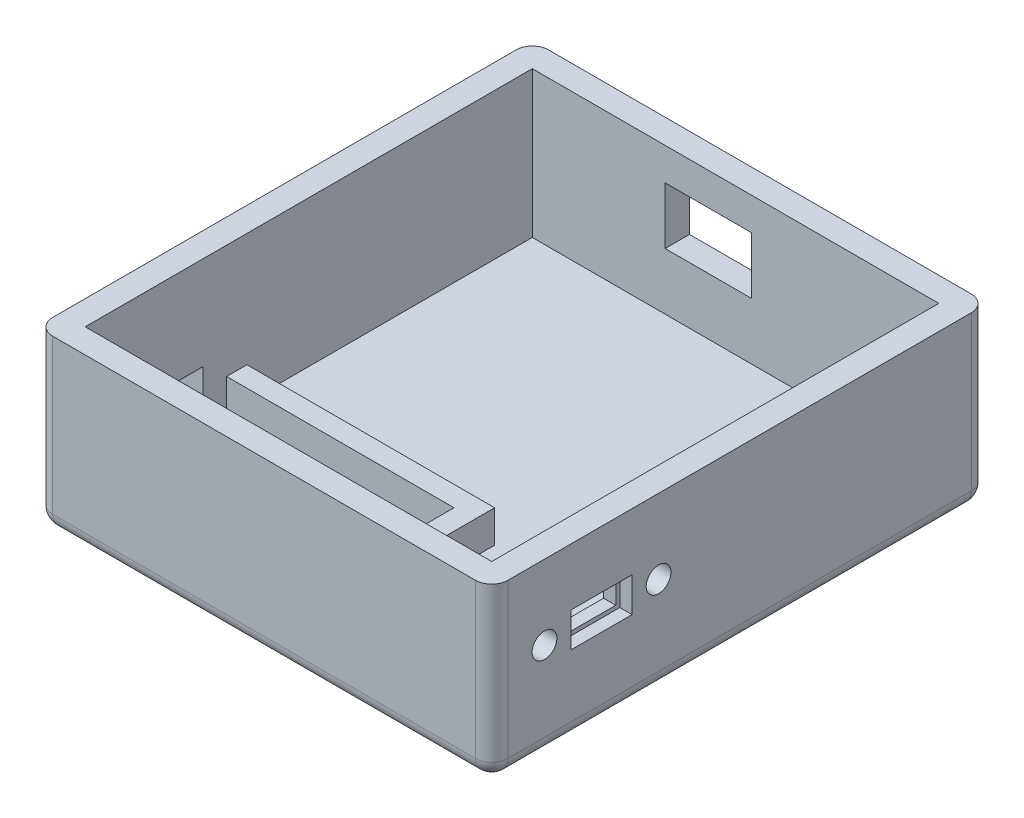
from build123d import *

# Parameters (mm, degrees)
SKETCH1_W           = 56.05
SKETCH1_H           = 61.05
SKETCH1_W_2         = 50.05
SKETCH1_H_2         = 55.05
BOSS_EXTRUDE1_DEPTH = 3
SKETCH1_3_W         = 56.05
SKETCH1_3_H         = 61.05
SKETCH1_3_W_2       = 50.05
SKETCH1_3_H_2       = 55.05
BOSS_EXTRUDE2_DEPTH = 21
CUT_EXTRUDE1_REACH  = 58.05
SKETCH2_R           = 1.525
SKETCH2_W           = 6.5
SKETCH2_H           = 3.25
CUT_EXTRUDE2_REACH  = 63.05
SKETCH3_W           = 10.65
SKETCH3_H           = 7
SKETCH4_W           = 11.05
SKETCH4_H           = 7
CUT_EXTRUDE3_DEPTH  = 3
BOSS_EXTRUDE3_DEPTH = 4
FILLET1_R           = 2
SKETCH6_W           = 7.5
SKETCH6_H           = 4.25
CUT_EXTRUDE4_DEPTH  = 1.5


with BuildPart() as part:
    # Sketch1 → Boss-Extrude1 (new body)
    with BuildSketch(Plane(origin=(0, 0, 0), x_dir=(1, 0, 0), z_dir=(0, 1, 0))):
        Rectangle(SKETCH1_W, SKETCH1_H)
        Rectangle(SKETCH1_W_2, SKETCH1_H_2, mode=Mode.SUBTRACT)
        Rectangle(SKETCH1_W_2, SKETCH1_H_2)
    extrude(amount=BOSS_EXTRUDE1_DEPTH)

    # Sketch1_3 → Boss-Extrude2 (add)
    with BuildSketch(Plane(origin=(0, 0, 0), x_dir=(1, 0, 0), z_dir=(0, 1, 0))):
        Rectangle(SKETCH1_3_W, SKETCH1_3_H)
        Rectangle(SKETCH1_3_W_2, SKETCH1_3_H_2, mode=Mode.SUBTRACT)
    extrude(amount=BOSS_EXTRUDE2_DEPTH)

    # Sketch2 → Cut-Extrude1 (cut, up to next)
    with BuildSketch(Plane(origin=(28.025, 0, 0), x_dir=(0, 0, -1), z_dir=(1, 0, 0)), mode=Mode.PRIVATE) as cut_extrude1_sk1:
        with Locations((-24.025, 11.825)):
            Circle(SKETCH2_R)
    cut_extrude1_tool1 = extrude(cut_extrude1_sk1.sketch, amount=-CUT_EXTRUDE1_REACH, mode=Mode.PRIVATE) & part.part
    add(cut_extrude1_tool1.solids().sort_by_distance((28.025, 11.825, 24.025))[0], mode=Mode.SUBTRACT)
    # Sketch2 → Cut-Extrude1 (cut, up to next)
    with BuildSketch(Plane(origin=(28.025, 0, 0), x_dir=(0, 0, -1), z_dir=(1, 0, 0)), mode=Mode.PRIVATE) as cut_extrude1_sk2:
        with Locations((-9.975, 11.825)):
            Circle(SKETCH2_R)
    cut_extrude1_tool2 = extrude(cut_extrude1_sk2.sketch, amount=-CUT_EXTRUDE1_REACH, mode=Mode.PRIVATE) & part.part
    add(cut_extrude1_tool2.solids().sort_by_distance((28.025, 11.825, 9.975))[0], mode=Mode.SUBTRACT)
    # Sketch2 → Cut-Extrude1 (cut, up to next)
    with BuildSketch(Plane(origin=(28.025, 0, 0), x_dir=(0, 0, -1), z_dir=(1, 0, 0)), mode=Mode.PRIVATE) as cut_extrude1_sk3:
        with Locations((-17, 11.825)):
            Rectangle(SKETCH2_W, SKETCH2_H)
    cut_extrude1_tool3 = extrude(cut_extrude1_sk3.sketch, amount=-CUT_EXTRUDE1_REACH, mode=Mode.PRIVATE) & part.part
    add(cut_extrude1_tool3.solids().sort_by_distance((28.025, 11.825, 17))[0], mode=Mode.SUBTRACT)

    # Sketch3 → Cut-Extrude2 (cut, up to next)
    with BuildSketch(Plane(origin=(0, 0, -30.525), x_dir=(-1, 0, 0), z_dir=(0, 0, -1)), mode=Mode.PRIVATE) as cut_extrude2_sk1:
        with Locations((3.35, 13.5)):
            Rectangle(SKETCH3_W, SKETCH3_H)
    cut_extrude2_tool1 = extrude(cut_extrude2_sk1.sketch, amount=-CUT_EXTRUDE2_REACH, mode=Mode.PRIVATE) & part.part
    add(cut_extrude2_tool1.solids().sort_by_distance((-3.35, 13.5, -30.525))[0], mode=Mode.SUBTRACT)

    # Sketch4 → Cut-Extrude3 (cut)
    with BuildSketch(Plane.ZY.offset(28.025)):
        with Locations((18.54, 6)):
            Rectangle(SKETCH4_W, SKETCH4_H)
    extrude(amount=-CUT_EXTRUDE3_DEPTH, mode=Mode.SUBTRACT)

    # Sketch5 → Boss-Extrude3 (add)
    with BuildSketch(Plane(origin=(0, 3, 0), x_dir=(1, 0, 0), z_dir=(0, 1, 0))):
        Polygon((5.475, -7.615), (-25.025, -7.615), (-25.025, -10.115), (2.975, -10.115), (2.975, -27.525), (5.475, -27.525), align=None)
    extrude(amount=BOSS_EXTRUDE3_DEPTH)

    # Fillet1
    fillet1_edges = [part.edges().sort_by_distance(p)[0] for p in [
        (-28.025, 0, 0),
        (0, 0, -30.525),
        (28.025, 0, 0),
        (0, 0, 30.525),
        (-28.025, 10.5, 30.525),
        (-28.025, 10.5, -30.525),
        (28.025, 10.5, -30.525),
        (28.025, 10.5, 30.525),
    ]]
    fillet(fillet1_edges, radius=FILLET1_R)

    # Sketch6 → Cut-Extrude4 (cut)
    with BuildSketch(Plane(origin=(28.025, 0, 0), x_dir=(0, 0, -1), z_dir=(1, 0, 0))):
        with Locations((-17, 11.825)):
            Rectangle(SKETCH6_W, SKETCH6_H)
    extrude(amount=-CUT_EXTRUDE4_DEPTH, mode=Mode.SUBTRACT)


solid = part.part
